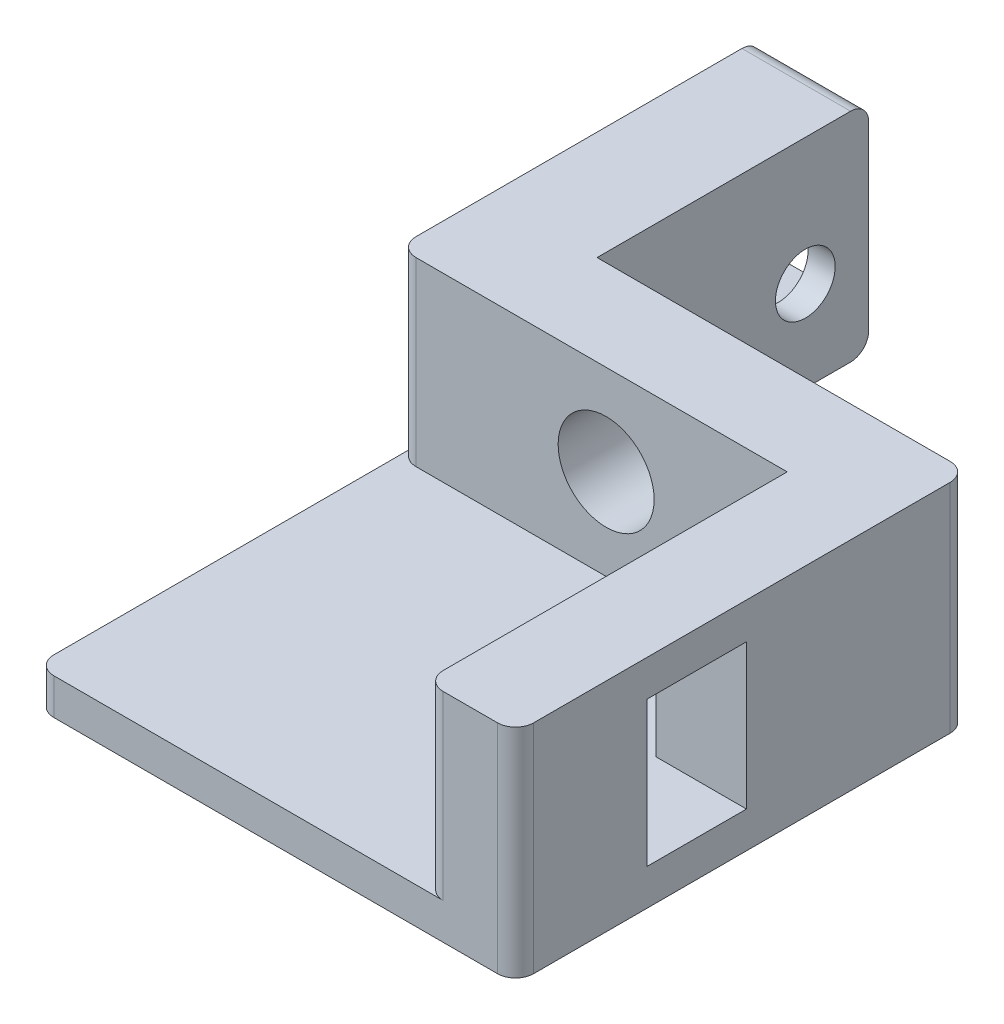
from build123d import *

# Parameters (mm, degrees)
RESSALTO_EXTRUS_O1_DEPTH = 10
RESSALTO_EXTRUS_O2_DEPTH = 2
ESBO_O2_W                = 5.5
ESBO_O2_H                = 8
CORTE_EXTRUS_O1_DEPTH    = 10
ESBO_O3_R                = 1.65
CORTE_EXTRUS_O2_DEPTH    = 10
ESBO_O4_R                = 2.65
CORTE_EXTRUS_O3_DEPTH    = 10
CORTE_EXTRUS_O4_START    = -1.5
CORTE_EXTRUS_O4_DEPTH    = 3
FILETE1_R                = 1


with BuildPart() as part:
    # Esboço1 → Ressalto-extrusão1 (new body)
    with BuildSketch(Plane(origin=(0, 0, 0), x_dir=(1, 0, 0), z_dir=(0, 1, 0))):
        Polygon((0, 0), (0, 20), (6, 20), (6, 5), (26.5, 5), (26.5, -20), (21.5, -20), (21.5, 0), align=None)
    extrude(amount=RESSALTO_EXTRUS_O1_DEPTH)

    # Esboço8 → Ressalto-extrusão2 (add)
    with BuildSketch(Plane.XZ):
        Polygon((26.5, -5), (6, -5), (6, -20), (0, -20), (0, 20), (26.5, 20), align=None)
    extrude(amount=RESSALTO_EXTRUS_O2_DEPTH)

    # Esboço2 → Corte-extrusão1 (cut)
    with BuildSketch(Plane.ZY.offset(-21.5)):
        with Locations((10, 4)):
            Rectangle(ESBO_O2_W, ESBO_O2_H)
    extrude(amount=-CORTE_EXTRUS_O1_DEPTH, mode=Mode.SUBTRACT)

    # Esboço3 → Corte-extrusão2 (cut)
    with BuildSketch(Plane(origin=(6, 0, 0), x_dir=(0, 0, -1), z_dir=(1, 0, 0))):
        with Locations((16.5, 3)):
            Circle(ESBO_O3_R)
    extrude(amount=-CORTE_EXTRUS_O2_DEPTH, mode=Mode.SUBTRACT)

    # Esboço4 → Corte-extrusão3 (cut)
    with BuildSketch(Plane(origin=(0, 0, -5), x_dir=(-1, 0, 0), z_dir=(0, 0, -1))):
        with Locations((-11.5, 5)):
            Circle(ESBO_O4_R)
    extrude(amount=-CORTE_EXTRUS_O3_DEPTH, mode=Mode.SUBTRACT)

    # Esboço7 → Corte-extrusão4 (cut)
    with BuildSketch(Plane.ZY.offset(CORTE_EXTRUS_O4_START)):
        Polygon((-13.035898385, 3), (-14.767949192, 6), (-18.232050808, 6), (-20, 6), (-20, 0), (-18.232050808, 0), (-14.767949192, 0), align=None)
    extrude(amount=-CORTE_EXTRUS_O4_DEPTH, mode=Mode.SUBTRACT)

    # Filete1
    filete1_edges = [part.edges().sort_by_distance(p)[0] for p in [
        (3, 10, -20),
        (21.5, 5, 20),
        (26.5, 4, 20),
        (26.5, 4, -5),
        (0, 5, 0),
        (0, -1, 20),
        (3, -2, -20),
    ]]
    fillet(filete1_edges, radius=FILETE1_R)


solid = part.part
